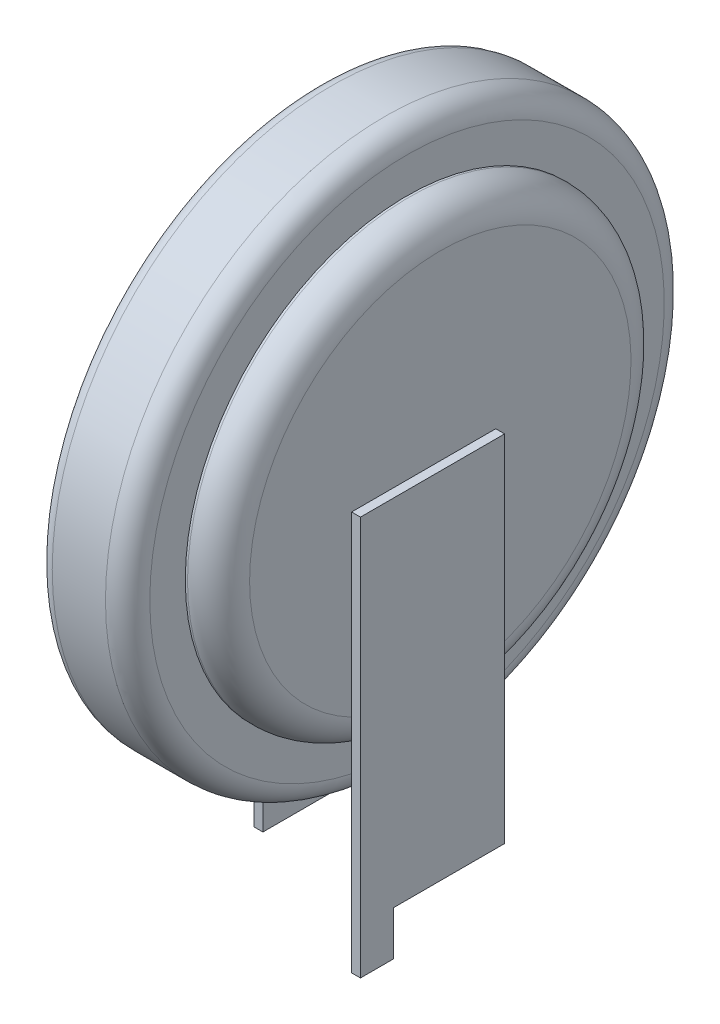
from build123d import *

# Parameters (mm, degrees)
BOSS_EXTRUDE2_DEPTH = 0.2
BOSS_EXTRUDE3_DEPTH = 0.2


with BuildPart() as part:
    # Sketch1 → Revolve1 (revolve)
    with BuildSketch(Plane.XY):
        with BuildLine():
            Line((-1.375, 7.8), (1.375, 7.8))
            Line((1.375, 7.8), (1.375, 12.1))
            ThreePointArc((1.375, 12.1), (1.169974747, 12.594974747), (0.675, 12.8))
            Line((0.675, 12.8), (0.625, 12.8))
            Line((0.625, 12.8), (0.625, 13.6))
            ThreePointArc((0.625, 13.6), (0.478553391, 13.953553391), (0.125, 14.1))
            Line((0.125, 14.1), (-1.075, 14.1))
            ThreePointArc((-1.075, 14.1), (-1.287132034, 14.012132034), (-1.375, 13.8))
            Line((-1.375, 13.8), (-1.375, 7.8))
        make_face()
    revolve(axis=Axis((-11.93322357, 7.8, 0), (1, 0, 0)))

    # Sketch3 → Boss-Extrude2 (add)
    with BuildSketch(Plane(origin=(1.375, 0, 0), x_dir=(0, 0, -1), z_dir=(1, 0, 0))):
        Polygon((-2, 8), (-2, -1), (-1.25, -1), (-1.25, 0), (1.25, 0), (1.25, 8), align=None)
    extrude(amount=BOSS_EXTRUDE2_DEPTH)

    # Sketch5 → Boss-Extrude3 (add)
    with BuildSketch(Plane(origin=(-1.375, 0, -1.375), x_dir=(0, 0, -1), z_dir=(1, 0, 0))):
        Polygon((0.625, -1), (0.625, 8), (-2.625, 8), (-2.625, 0), (-0.125, 0), (-0.125, -1), align=None)
    extrude(amount=-BOSS_EXTRUDE3_DEPTH)


solid = part.part
